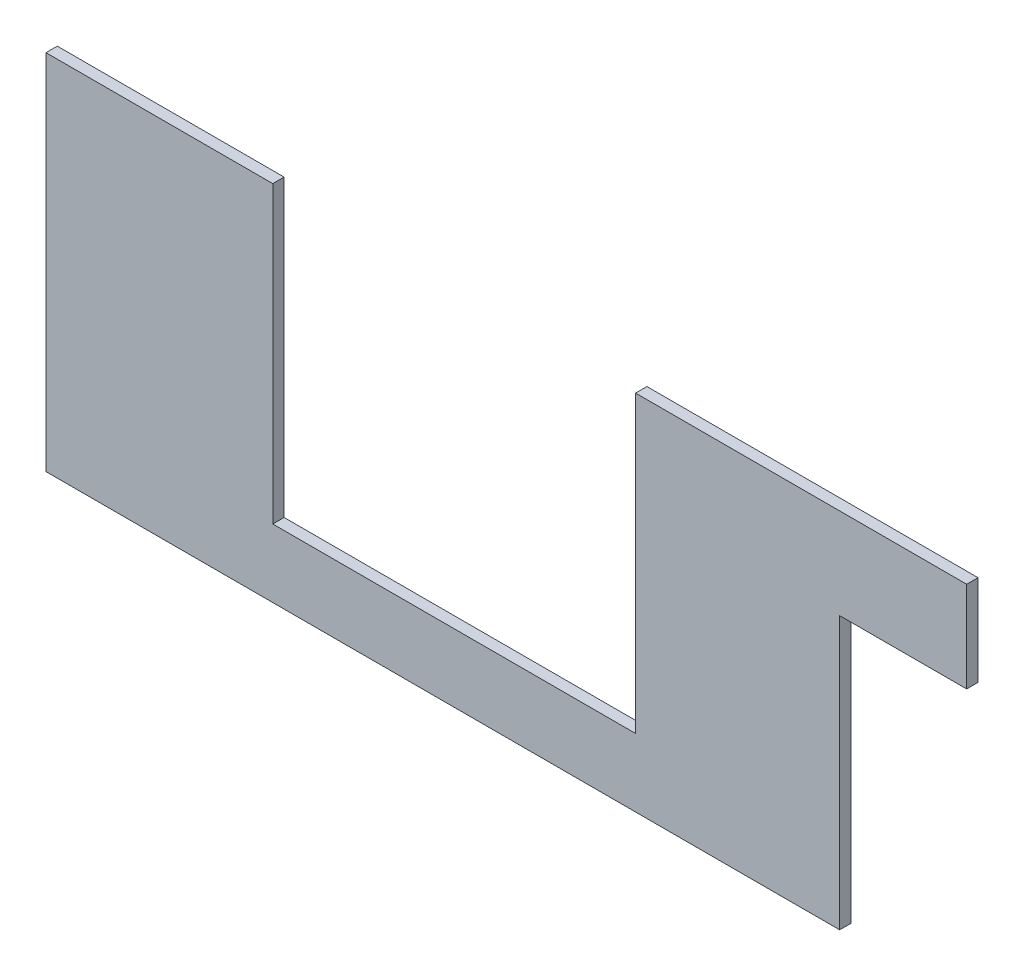
from build123d import *

# Parameters (mm, degrees)
BOSS_EXTRUDE1_DEPTH = 3.175


with BuildPart() as part:
    # Sketch1 → Boss-Extrude1 (new body)
    with BuildSketch(Plane.XY):
        Polygon((257.81, 76.2), (222.25, 76.2), (222.25, 0), (0, 0), (0, 101.6), (63.5, 101.6), (63.5, 19.05), (165.1, 19.05), (165.1, 101.6), (257.81, 101.6), align=None)
    extrude(amount=BOSS_EXTRUDE1_DEPTH)


solid = part.part
